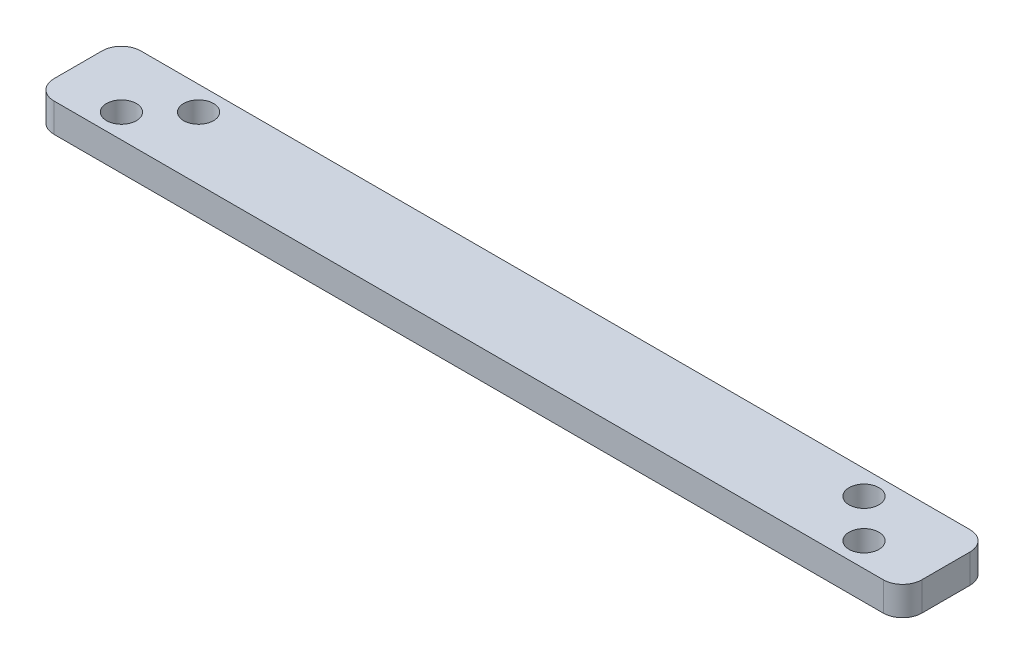
from build123d import *

# Parameters (mm, degrees)
SKETCH_1_W      = 90
SKETCH_1_H      = 9
SKETCH_1_R      = 1.55
EXTRUDE_2_DEPTH = 3
FILLET_1_R      = 2


with BuildPart() as part:
    # 草图1 → 凸台-拉伸2 (new body)
    with BuildSketch(Plane(origin=(0, 0, 0), x_dir=(1, 0, 0), z_dir=(0, 1, 0))):
        Rectangle(SKETCH_1_W, SKETCH_1_H)
        with Locations((-38.5, -2)):
            Circle(SKETCH_1_R, mode=Mode.SUBTRACT)
        with Locations((-34.5, 2)):
            Circle(SKETCH_1_R, mode=Mode.SUBTRACT)
        with Locations((38.5, -2)):
            Circle(SKETCH_1_R, mode=Mode.SUBTRACT)
        with Locations((34.5, 2)):
            Circle(SKETCH_1_R, mode=Mode.SUBTRACT)
    extrude(amount=EXTRUDE_2_DEPTH)

    # 圆角1
    fillet_1_edges = [part.edges().sort_by_distance(p)[0] for p in [
        (45, 1.5, 4.5),
        (-45, 1.5, 4.5),
        (-45, 1.5, -4.5),
        (45, 1.5, -4.5),
    ]]
    fillet(fillet_1_edges, radius=FILLET_1_R)


solid = part.part
